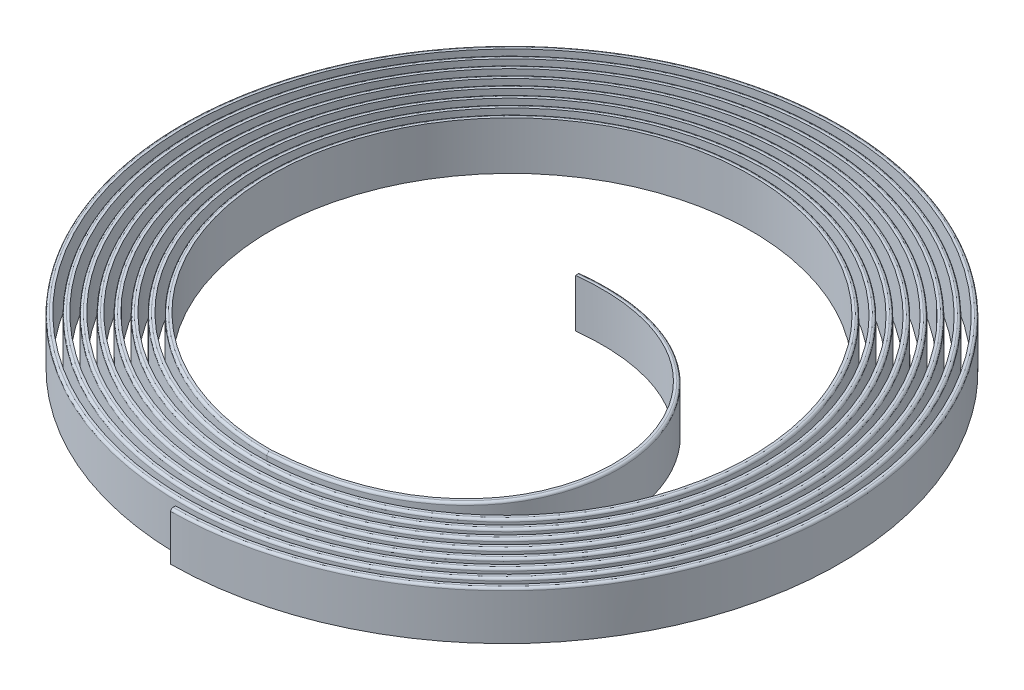
from build123d import *

# Parameters (mm, degrees)
SKETCH3_W = 0.1
SKETCH3_H = 1
FILLET1_R = 0.05


with BuildPart() as part:
    # Sweep1: sweep along a curve in space
    with BuildLine() as sweep1_path:
        add(Edge.make_bspline(
            [(0, 0, 7), (0.916297857, 0, 6.994791667), (1.830138523, 0, 6.807402286), (3.515470673, 0, 6.098039934), (4.286305303, 0, 5.576361156), (5.56899546, 0, 4.278939607), (6.080357854, 0, 3.503718866), (6.767341895, 0, 1.817972616), (6.942708333, 0, 0.908116626), (6.932291667, 0, -0.908116626), (6.746528994, 0, -1.81377928), (6.043428284, 0, -3.483994487), (5.526381978, 0, -4.247896133), (4.240530437, 0, -5.519016282), (3.472242679, 0, -6.025746205), (1.801613373, 0, -6.706468603), (0.899935396, 0, -6.880208333), (-0.899935396, 0, -6.869791667), (-1.797420037, 0, -6.685655702), (-3.452518301, 0, -5.988816635), (-4.209486963, 0, -5.4764028), (-5.469037105, 0, -4.202121267), (-5.971134556, 0, -3.440766493), (-6.64559531, 0, -1.78525413), (-6.817708333, 0, -0.891754165), (-6.807291667, 0, 0.891754165), (-6.624782409, 0, 1.781060794), (-5.934204986, 0, 3.421042114), (-5.426423623, 0, 4.171077793), (-4.163712097, 0, 5.419057927), (-3.409290307, 0, 5.916522906), (-1.768894887, 0, 6.584722018), (-0.883572934, 0, 6.755208333), (0.883572934, 0, 6.744791667), (1.764701552, 0, 6.563909117), (3.389565928, 0, 5.879593337), (4.132668623, 0, 5.376444445), (5.36907875, 0, 4.125302927), (5.861911257, 0, 3.377814121), (6.523848726, 0, 1.752535644), (6.692708333, 0, 0.875391703), (6.682291667, 0, -0.875391703), (6.503035825, 0, -1.748342309), (5.824981687, 0, -3.358089742), (5.326465268, 0, -4.094259453), (4.086893757, 0, -5.319099572), (3.346337934, 0, -5.807299608), (1.736176402, 0, -6.462975433), (0.867210472, 0, -6.630208333), (-0.867210472, 0, -6.619791667), (-1.731983066, 0, -6.442162532), (-3.326613556, 0, -5.770370038), (-4.055850283, 0, -5.27648609), (-5.269120394, 0, -4.048484587), (-5.752687958, 0, -3.314861748), (-6.402102141, 0, -1.719817159), (-6.567708333, 0, -0.859029241), (-6.557291667, 0, 0.859029241), (-6.38128924, 0, 1.715623823), (-5.715758389, 0, 3.295137369), (-5.226506912, 0, 4.017441113), (-4.010075417, 0, 5.219141217), (-3.283385562, 0, 5.698076309), (-1.703457916, 0, 6.341228849), (-0.85084801, 0, 6.505208333), (0.85084801, 0, 6.494791667), (1.699264581, 0, 6.320415948), (3.263661183, 0, 5.661146739), (3.979031943, 0, 5.176527735), (5.169162039, 0, 3.971666247), (5.64346466, 0, 3.251909376), (6.280355557, 0, 1.687098673), (6.442708333, 0, 0.842666779), (6.432291667, 0, -0.842666779), (6.259542656, 0, -1.682905338), (5.60653509, 0, -3.232184997), (5.126548557, 0, -3.940622773), (3.933257077, 0, -5.119182861), (3.220433189, 0, -5.588853011), (1.670739431, 0, -6.219482264), (0.834485549, 0, -6.380208333), (-0.834485549, 0, -6.369791667), (-1.666546095, 0, -6.198669363), (-3.20070881, 0, -5.551923441), (-3.902213603, 0, -5.076569379), (-5.069203684, 0, -3.894847907), (-5.534241361, 0, -3.188957003), (-6.158608972, 0, -1.654380188), (-6.317708333, 0, -0.826304318), (-6.307291667, 0, 0.826304318), (-6.137796071, 0, 1.650186852), (-5.497311792, 0, 3.169232624), (-5.026590202, 0, 3.863804433), (-3.856438737, 0, 5.019224506), (-3.157480817, 0, 5.479629712), (-1.638020945, 0, 6.09773568), (-0.818123087, 0, 6.255208333), (0.818123087, 0, 6.244791667), (1.633827609, 0, 6.076922779), (3.137756438, 0, 5.442700142), (3.825395263, 0, 4.976611024), (4.969245328, 0, 3.818029567), (5.425018063, 0, 3.12600463), (6.036862387, 0, 1.621661702), (6.192708333, 0, 0.809941856), (6.182291667, 0, -0.809941856), (6.016049486, 0, -1.617468367), (5.388088493, 0, -3.106280252), (4.926631846, 0, -3.786986093), (3.779620397, 0, -4.919266151), (3.094528444, 0, -5.370406414), (1.60530246, 0, -5.975989095), (0.801760625, 0, -6.130208333), (-0.801760625, 0, -6.119791667), (-1.601109124, 0, -5.955176194), (-3.074804065, 0, -5.333476844), (-3.748576923, 0, -4.876652669), (-4.869286973, 0, -3.741211227), (-5.315794764, 0, -3.063052258), (-5.915115803, 0, -1.588943217), (-6.067708333, 0, -0.793579394), (-6.057291667, 0, 0.793579394), (-5.894302902, 0, 1.584749881), (-5.278865195, 0, 3.043327879), (-4.826673491, 0, 3.710167753), (-3.702802057, 0, 4.819307795), (-3.031576072, 0, 5.261183115), (-1.572583974, 0, 5.854242511), (-0.785398163, 0, 6.005208333), (0.785398163, 0, 5.994791667), (1.568390638, 0, 5.83342961), (3.011851693, 0, 5.224253545), (3.671758583, 0, 4.776694313), (4.769328618, 0, 3.664392887), (5.206571466, 0, 3.000099885), (5.793369218, 0, 1.556224731), (5.942708333, 0, 0.777216933), (5.932291667, 0, -0.777216933), (5.772556317, 0, -1.552031396), (5.169641896, 0, -2.980375507), (4.726715136, 0, -3.633349413), (3.625983717, 0, -4.71934944), (2.968623699, 0, -5.151959816), (1.539865488, 0, -5.732495926), (0.769035702, 0, -5.880208333), (-0.769035702, 0, -5.869791667), (-1.535672153, 0, -5.711683025), (-2.94889932, 0, -5.115030247), (-3.594940243, 0, -4.676735958), (-4.669370262, 0, -3.587574547), (-5.097348167, 0, -2.937147513), (-5.671622634, 0, -1.523506246), (-5.817708333, 0, -0.760854471), (-5.807291667, 0, 0.760854471), (-5.650809733, 0, 1.51931291), (-5.060418597, 0, 2.917423134), (-4.62675678, 0, 3.556531073), (-3.549165377, 0, 4.619391085), (-2.905671327, 0, 5.042736518), (-1.507147003, 0, 5.610749341), (-0.75267324, 0, 5.755208333), (0.75267324, 0, 5.744791667), (1.502953667, 0, 5.58993644), (2.885946948, 0, 5.005806948), (3.518121903, 0, 4.576777603), (4.569411907, 0, 3.510756207), (4.988124869, 0, 2.87419514), (5.549876049, 0, 1.49078776), (5.692708333, 0, 0.744492009), (5.682291667, 0, -0.744492009), (5.529063148, 0, -1.486594424), (4.951195299, 0, -2.854470761), (4.526798425, 0, -3.479712733), (3.472347037, 0, -4.519432729), (2.842718954, 0, -4.933513219), (1.474428517, 0, -5.489002757), (0.736310778, 0, -5.630208333), (-0.736310778, 0, -5.619791667), (-1.470235182, 0, -5.468189856), (-2.822994575, 0, -4.89658365), (-3.441303563, 0, -4.476819247), (-4.469453552, 0, -3.433937867), (-4.87890157, 0, -2.811242768), (-5.428129464, 0, -1.458069275), (-5.567708333, 0, -0.728129547), (-5.557291667, 0, 0.728129547), (-5.407316563, 0, 1.453875939), (-4.841972, 0, 2.791518389), (-4.42684007, 0, 3.402894393), (-3.395528697, 0, 4.419474374), (-2.779766581, 0, 4.824289921), (-1.441710032, 0, 5.367256172), (-0.719948316, 0, 5.505208333), (0.719948316, 0, 5.494791667), (1.437516696, 0, 5.346443271), (2.760042203, 0, 4.787360351), (3.364485223, 0, 4.376860892), (4.369495197, 0, 3.357119527), (4.769678272, 0, 2.748290395), (5.30638288, 0, 1.425350789), (5.442708333, 0, 0.711767086), (5.432291667, 0, -0.711767086), (5.285569979, 0, -1.421157453), (4.732748702, 0, -2.728566016), (4.326881715, 0, -3.326076053), (3.318710357, 0, -4.319516019), (2.716814209, 0, -4.715066622), (1.408991546, 0, -5.245509588), (0.703585855, 0, -5.380208333), (-0.703585855, 0, -5.369791667), (-1.404798211, 0, -5.224696687), (-2.69708983, 0, -4.678137053), (-3.287666883, 0, -4.276902537), (-4.269536841, 0, -3.280301187), (-4.660454973, 0, -2.685338023), (-5.184636295, 0, -1.392632303), (-5.317708333, 0, -0.695404624), (-5.307291667, 0, 0.695404624), (-5.163823394, 0, 1.388438968), (-4.623525403, 0, 2.665613644), (-4.226923359, 0, 3.249257713), (-3.241892017, 0, 4.219557664), (-2.653861836, 0, 4.605843324), (-1.376273061, 0, 5.123763003), (-0.687223393, 0, 5.255208333), (0.687223393, 0, 5.244791667), (1.372079725, 0, 5.102950102), (2.634137458, 0, 4.568913754), (3.210848543, 0, 4.176944182), (4.169578486, 0, 3.203482847), (4.551231674, 0, 2.62238565), (5.062889711, 0, 1.359913818), (5.192708333, 0, 0.679042162), (5.182291667, 0, -0.679042162), (5.04207681, 0, -1.355720482), (4.514302105, 0, -2.602661271), (4.126965004, 0, -3.172439373), (3.165073677, 0, -4.119599308), (2.590909464, 0, -4.496620025), (1.343554575, 0, -5.002016418), (0.670860931, 0, -5.130208333), (-0.670860931, 0, -5.119791667), (-1.33936124, 0, -4.981203517), (-2.571185085, 0, -4.459690455), (-3.134030203, 0, -4.076985826), (-4.069620131, 0, -3.126664507), (-4.442008376, 0, -2.559433278), (-4.941143126, 0, -1.327195332), (-5.067708333, 0, -0.6626797), (-5.057291667, 0, 0.6626797), (-4.920330225, 0, 1.323001997), (-4.405078806, 0, 2.539708899), (-4.027006649, 0, 3.095621033), (-3.088255337, 0, 4.019640953), (-2.527957091, 0, 4.387396727), (-1.31083609, 0, 4.880269834), (-0.654498469, 0, 5.005208333), (0, 0, 5)],
            knots=[0, 0, 0, 0, 0.0078125, 0.0078125, 0.015625, 0.015625, 0.0234375, 0.0234375, 0.03125, 0.03125, 0.0390625, 0.0390625, 0.046875, 0.046875, 0.0546875, 0.0546875, 0.0625, 0.0625, 0.0703125, 0.0703125, 0.078125, 0.078125, 0.0859375, 0.0859375, 0.09375, 0.09375, 0.1015625, 0.1015625, 0.109375, 0.109375, 0.1171875, 0.1171875, 0.125, 0.125, 0.1328125, 0.1328125, 0.140625, 0.140625, 0.1484375, 0.1484375, 0.15625, 0.15625, 0.1640625, 0.1640625, 0.171875, 0.171875, 0.1796875, 0.1796875, 0.1875, 0.1875, 0.1953125, 0.1953125, 0.203125, 0.203125, 0.2109375, 0.2109375, 0.21875, 0.21875, 0.2265625, 0.2265625, 0.234375, 0.234375, 0.2421875, 0.2421875, 0.25, 0.25, 0.2578125, 0.2578125, 0.265625, 0.265625, 0.2734375, 0.2734375, 0.28125, 0.28125, 0.2890625, 0.2890625, 0.296875, 0.296875, 0.3046875, 0.3046875, 0.3125, 0.3125, 0.3203125, 0.3203125, 0.328125, 0.328125, 0.3359375, 0.3359375, 0.34375, 0.34375, 0.3515625, 0.3515625, 0.359375, 0.359375, 0.3671875, 0.3671875, 0.375, 0.375, 0.3828125, 0.3828125, 0.390625, 0.390625, 0.3984375, 0.3984375, 0.40625, 0.40625, 0.4140625, 0.4140625, 0.421875, 0.421875, 0.4296875, 0.4296875, 0.4375, 0.4375, 0.4453125, 0.4453125, 0.453125, 0.453125, 0.4609375, 0.4609375, 0.46875, 0.46875, 0.4765625, 0.4765625, 0.484375, 0.484375, 0.4921875, 0.4921875, 0.5, 0.5, 0.5078125, 0.5078125, 0.515625, 0.515625, 0.5234375, 0.5234375, 0.53125, 0.53125, 0.5390625, 0.5390625, 0.546875, 0.546875, 0.5546875, 0.5546875, 0.5625, 0.5625, 0.5703125, 0.5703125, 0.578125, 0.578125, 0.5859375, 0.5859375, 0.59375, 0.59375, 0.6015625, 0.6015625, 0.609375, 0.609375, 0.6171875, 0.6171875, 0.625, 0.625, 0.6328125, 0.6328125, 0.640625, 0.640625, 0.6484375, 0.6484375, 0.65625, 0.65625, 0.6640625, 0.6640625, 0.671875, 0.671875, 0.6796875, 0.6796875, 0.6875, 0.6875, 0.6953125, 0.6953125, 0.703125, 0.703125, 0.7109375, 0.7109375, 0.71875, 0.71875, 0.7265625, 0.7265625, 0.734375, 0.734375, 0.7421875, 0.7421875, 0.75, 0.75, 0.7578125, 0.7578125, 0.765625, 0.765625, 0.7734375, 0.7734375, 0.78125, 0.78125, 0.7890625, 0.7890625, 0.796875, 0.796875, 0.8046875, 0.8046875, 0.8125, 0.8125, 0.8203125, 0.8203125, 0.828125, 0.828125, 0.8359375, 0.8359375, 0.84375, 0.84375, 0.8515625, 0.8515625, 0.859375, 0.859375, 0.8671875, 0.8671875, 0.875, 0.875, 0.8828125, 0.8828125, 0.890625, 0.890625, 0.8984375, 0.8984375, 0.90625, 0.90625, 0.9140625, 0.9140625, 0.921875, 0.921875, 0.9296875, 0.9296875, 0.9375, 0.9375, 0.9453125, 0.9453125, 0.953125, 0.953125, 0.9609375, 0.9609375, 0.96875, 0.96875, 0.9765625, 0.9765625, 0.984375, 0.984375, 0.9921875, 0.9921875, 1, 1, 1, 1], degree=3))
        add(Edge.make_bspline(
            [(0, 0, 5), (5.549002618, 0, 4.655747629), (4.815933618, 0, -2.030709219), (0, 0, -1.5)],
            knots=[0, 0, 0, 0, 1, 1, 1, 1], degree=3))
    # Sketch3 → Sweep1 (sweep)
    with BuildSketch(Plane(origin=(0, 0, 0), x_dir=(0, 0, -1), z_dir=(1, 0, 0))):
        with Locations((-6.95, 0.5)):
            Rectangle(SKETCH3_W, SKETCH3_H)
    sweep(path=sweep1_path.line, transition=Transition.RIGHT)

    # Fillet1
    fillet1_edges = [part.edges().sort_by_distance(p)[0] for p in [
        (-5.310945061, 1, -2.964936217),
    ]]
    fillet(fillet1_edges, radius=FILLET1_R)


solid = part.part
